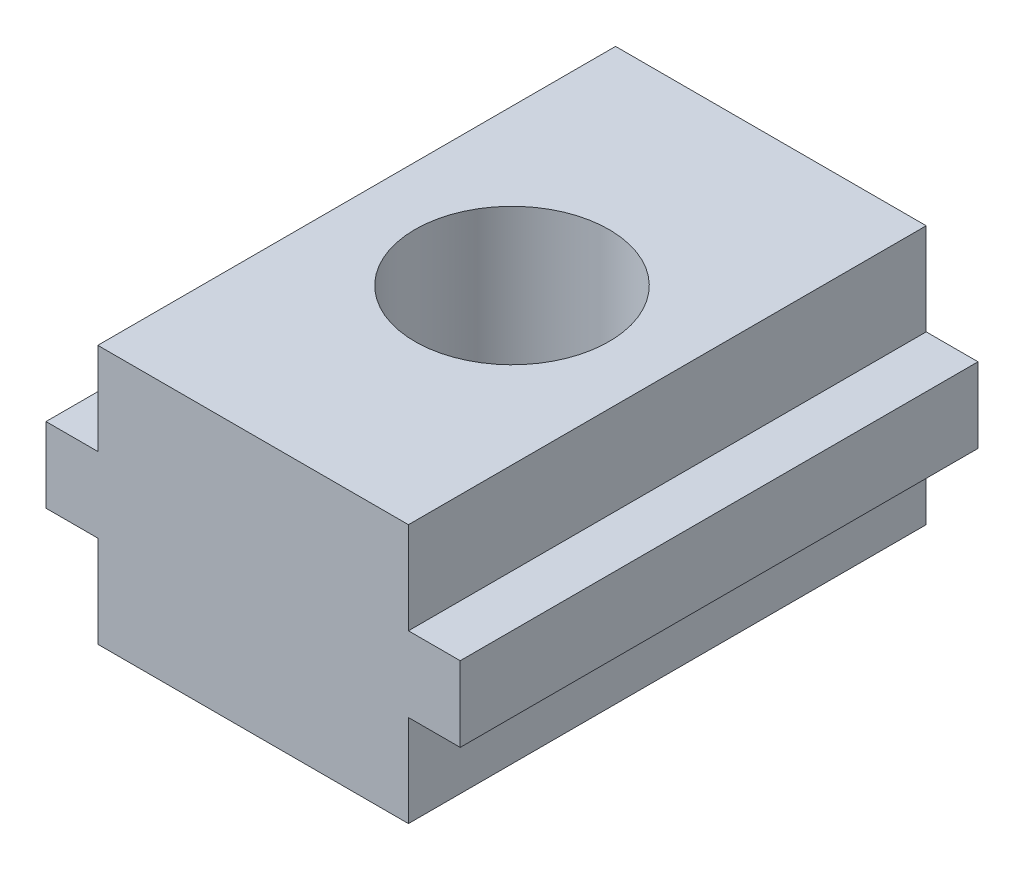
from build123d import *

# Parameters (mm, degrees)
BOSS_EXTRUDE1_DEPTH = 10
SKETCH2_R           = 3.75
CUT_EXTRUDE1_DEPTH  = 8
SKETCH3_R           = 3
CUT_EXTRUDE2_DEPTH  = 3


with BuildPart() as part:
    # Sketch1 → Boss-Extrude1 (new body, symmetric)
    with BuildSketch(Plane.XY):
        Polygon((-6, 10), (-6, 6.45), (-8, 6.45), (-8, 3.55), (-6, 3.55), (-6, 0), (6, 0), (6, 3.55), (8, 3.55), (8, 6.45), (6, 6.45), (6, 10), align=None)
    extrude(amount=BOSS_EXTRUDE1_DEPTH, both=True)

    # Sketch2 → Cut-Extrude1 (cut)
    with BuildSketch(Plane(origin=(0, 10, 0), x_dir=(1, 0, 0), z_dir=(0, 1, 0))):
        Circle(SKETCH2_R)
    extrude(amount=-CUT_EXTRUDE1_DEPTH, mode=Mode.SUBTRACT)

    # Sketch3 → Cut-Extrude2 (cut, through all)
    with BuildSketch(Plane(origin=(0, 2, 0), x_dir=(1, 0, 0), z_dir=(0, 1, 0))):
        Circle(SKETCH3_R)
    extrude(amount=-CUT_EXTRUDE2_DEPTH, mode=Mode.SUBTRACT)


solid = part.part
